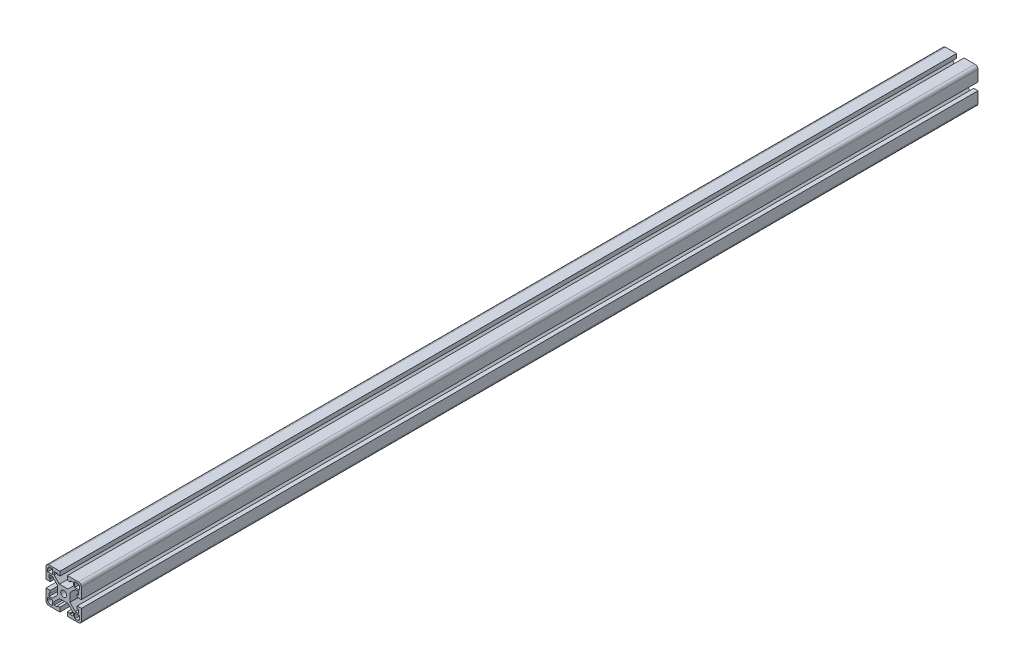
from build123d import *

# Parameters (mm, degrees)
SKETCH1_R      = 3.2639
FINALCUT_DEPTH = 965.2


with BuildPart() as part:
    # Sketch1 → FinalCut (new body)
    with BuildSketch(Plane.XY):
        with BuildLine():
            Line((-6.731, 0), (-6.731, 4.575738531))
            Line((-6.731, 4.575738531), (-12.442261469, 10.287))
            Line((-12.442261469, 10.287), (-15.6718, 10.287))
            Line((-15.6718, 10.287), (-15.6718, 6.858))
            Line((-15.6718, 6.858), (-14.478, 6.858))
            Line((-14.478, 6.858), (-14.478, 4.064))
            Line((-14.478, 4.064), (-19.05, 4.064))
            Line((-19.05, 4.064), (-19.05, 15.875))
            ThreePointArc((-19.05, 15.875), (-18.12006403, 18.12006403), (-15.875, 19.05))
            Line((-15.875, 19.05), (-4.064, 19.05))
            Line((-4.064, 19.05), (-4.064, 14.478))
            Line((-4.064, 14.478), (-6.858, 14.478))
            Line((-6.858, 14.478), (-6.858, 15.6718))
            Line((-6.858, 15.6718), (-10.287, 15.6718))
            Line((-10.287, 15.6718), (-10.287, 12.442261469))
            Line((-10.287, 12.442261469), (-4.575738531, 6.731))
            Line((-4.575738531, 6.731), (0, 6.731))
            Line((0, 6.731), (4.575738531, 6.731))
            Line((4.575738531, 6.731), (10.287, 12.442261469))
            Line((10.287, 12.442261469), (10.287, 15.6718))
            Line((10.287, 15.6718), (6.858, 15.6718))
            Line((6.858, 15.6718), (6.858, 14.478))
            Line((6.858, 14.478), (4.064, 14.478))
            Line((4.064, 14.478), (4.064, 19.05))
            Line((4.064, 19.05), (15.875, 19.05))
            ThreePointArc((15.875, 19.05), (18.12006403, 18.12006403), (19.05, 15.875))
            Line((19.05, 15.875), (19.05, 4.064))
            Line((19.05, 4.064), (14.478, 4.064))
            Line((14.478, 4.064), (14.478, 6.858))
            Line((14.478, 6.858), (15.6718, 6.858))
            Line((15.6718, 6.858), (15.6718, 10.287))
            Line((15.6718, 10.287), (12.442261469, 10.287))
            Line((12.442261469, 10.287), (6.731, 4.575738531))
            Line((6.731, 4.575738531), (6.731, 0))
            Line((6.731, 0), (6.731, -4.575738531))
            Line((6.731, -4.575738531), (12.442261469, -10.287))
            Line((12.442261469, -10.287), (15.6718, -10.287))
            Line((15.6718, -10.287), (15.6718, -6.858))
            Line((15.6718, -6.858), (14.478, -6.858))
            Line((14.478, -6.858), (14.478, -4.064))
            Line((14.478, -4.064), (19.05, -4.064))
            Line((19.05, -4.064), (19.05, -15.875))
            ThreePointArc((19.05, -15.875), (18.12006403, -18.12006403), (15.875, -19.05))
            Line((15.875, -19.05), (4.064, -19.05))
            Line((4.064, -19.05), (4.064, -14.478))
            Line((4.064, -14.478), (6.858, -14.478))
            Line((6.858, -14.478), (6.858, -15.6718))
            Line((6.858, -15.6718), (10.287, -15.6718))
            Line((10.287, -15.6718), (10.287, -12.442261469))
            Line((10.287, -12.442261469), (4.575738531, -6.731))
            Line((4.575738531, -6.731), (0, -6.731))
            Line((0, -6.731), (-4.575738531, -6.731))
            Line((-4.575738531, -6.731), (-10.287, -12.442261469))
            Line((-10.287, -12.442261469), (-10.287, -15.6718))
            Line((-10.287, -15.6718), (-6.858, -15.6718))
            Line((-6.858, -15.6718), (-6.858, -14.478))
            Line((-6.858, -14.478), (-4.064, -14.478))
            Line((-4.064, -14.478), (-4.064, -19.05))
            Line((-4.064, -19.05), (-15.875, -19.05))
            ThreePointArc((-15.875, -19.05), (-18.12006403, -18.12006403), (-19.05, -15.875))
            Line((-19.05, -15.875), (-19.05, -4.064))
            Line((-19.05, -4.064), (-14.478, -4.064))
            Line((-14.478, -4.064), (-14.478, -6.858))
            Line((-14.478, -6.858), (-15.6718, -6.858))
            Line((-15.6718, -6.858), (-15.6718, -10.287))
            Line((-15.6718, -10.287), (-12.442261469, -10.287))
            Line((-12.442261469, -10.287), (-6.731, -4.575738531))
            Line((-6.731, -4.575738531), (-6.731, 0))
        make_face()
        Circle(SKETCH1_R, mode=Mode.SUBTRACT)
        with BuildLine():
            Line((17.272, 11.8872), (17.272, 14.478))
            ThreePointArc((17.272, 14.478), (16.453656347, 16.453656347), (14.478, 17.272))
            Line((14.478, 17.272), (11.8872, 17.272))
            Line((11.8872, 17.272), (11.8872, 11.8872))
            Line((11.8872, 11.8872), (17.272, 11.8872))
        make_face(mode=Mode.SUBTRACT)
        with BuildLine():
            Line((11.8872, -11.8872), (17.272, -11.8872))
            Line((17.272, -11.8872), (17.272, -14.478))
            ThreePointArc((17.272, -14.478), (16.453656347, -16.453656347), (14.478, -17.272))
            Line((14.478, -17.272), (11.8872, -17.272))
            Line((11.8872, -17.272), (11.8872, -11.8872))
        make_face(mode=Mode.SUBTRACT)
        with BuildLine():
            Line((-17.272, -11.8872), (-17.272, -14.478))
            ThreePointArc((-17.272, -14.478), (-16.453656347, -16.453656347), (-14.478, -17.272))
            Line((-14.478, -17.272), (-11.8872, -17.272))
            Line((-11.8872, -17.272), (-11.8872, -11.8872))
            Line((-11.8872, -11.8872), (-17.272, -11.8872))
        make_face(mode=Mode.SUBTRACT)
        with BuildLine():
            Line((-11.8872, 11.8872), (-17.272, 11.8872))
            Line((-17.272, 11.8872), (-17.272, 14.478))
            ThreePointArc((-17.272, 14.478), (-16.453656347, 16.453656347), (-14.478, 17.272))
            Line((-14.478, 17.272), (-11.8872, 17.272))
            Line((-11.8872, 17.272), (-11.8872, 11.8872))
        make_face(mode=Mode.SUBTRACT)
    extrude(amount=-FINALCUT_DEPTH)


solid = part.part
